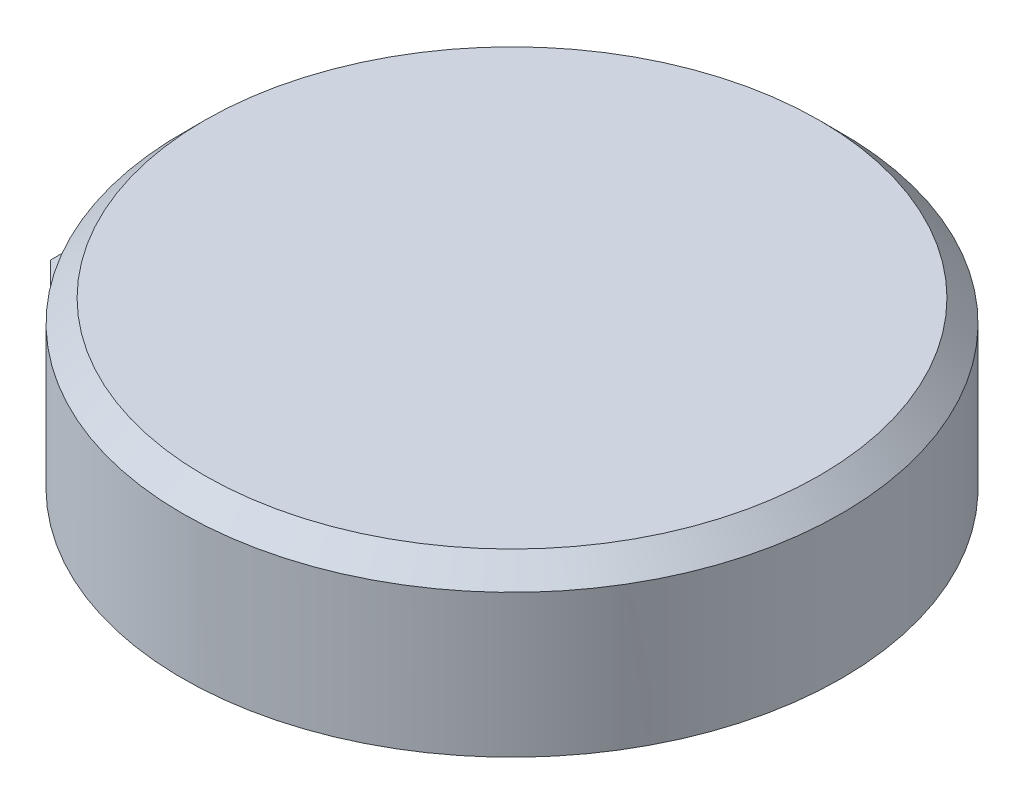
from build123d import *

# Parameters (mm, degrees)
SKETCH1_R           = 150
BOSS_EXTRUDE1_DEPTH = 75
CHAMFER1_SIZE       = 10
SKETCH2_W           = 70
SKETCH2_H           = 70
BOSS_EXTRUDE2_DEPTH = 10
CHAMFER2_SIZE       = 10


with BuildPart() as part:
    # Sketch1 → Boss-Extrude1 (new body)
    with BuildSketch(Plane(origin=(0, 0, 0), x_dir=(1, 0, 0), z_dir=(0, 1, 0))):
        Circle(SKETCH1_R)
    extrude(amount=BOSS_EXTRUDE1_DEPTH)

    # Chamfer1
    chamfer1_edges = [part.edges().sort_by_distance(p)[0] for p in [
        (-150, 75, 0),
    ]]
    chamfer(chamfer1_edges, length=CHAMFER1_SIZE)

    # Sketch2 → Boss-Extrude2 (add)
    with BuildSketch(Plane.XZ):
        with Locations((-150, 0)):
            Rectangle(SKETCH2_W, SKETCH2_H)
    extrude(amount=-BOSS_EXTRUDE2_DEPTH)

    # Chamfer2
    chamfer2_edges = [part.edges().sort_by_distance(p)[0] for p in [
        (-185, 5, 35),
    ]]
    chamfer(chamfer2_edges, length=CHAMFER2_SIZE)


solid = part.part
